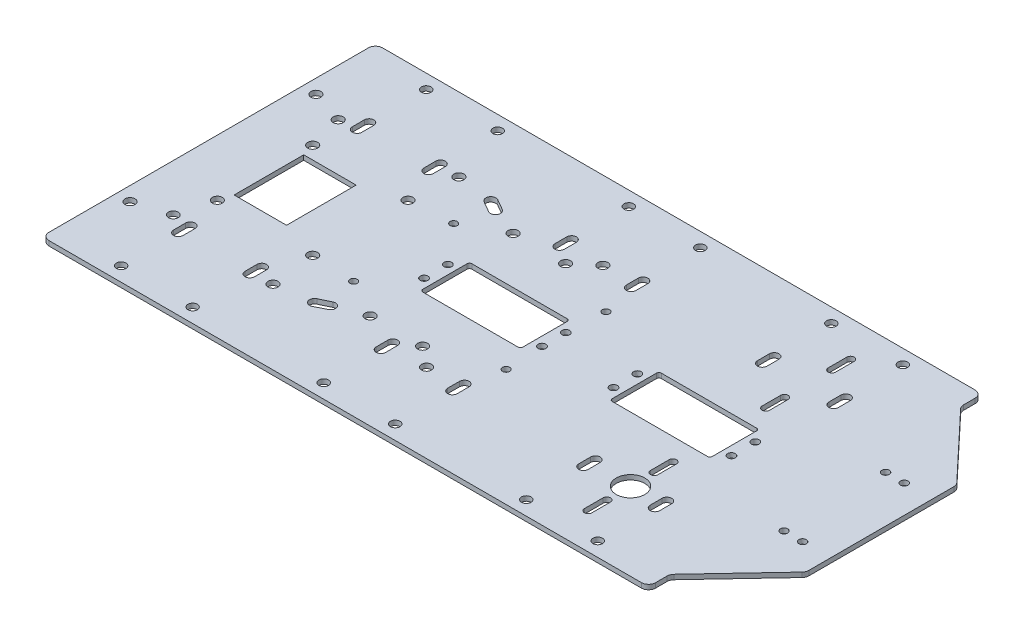
from build123d import *

# Parameters (mm, degrees)
SKETCH_1_R      = 2.1
SKETCH_1_R_2    = 2.05
SKETCH_1_R_3    = 1.55
SKETCH_1_R_4    = 2
SKETCH_1_R_5    = 1.6
SKETCH_1_R_6    = 1.5
SKETCH_1_R_7    = 6
SKETCH_1_W      = 22
SKETCH_1_H      = 29.2
EXTRUDE_1_DEPTH = 2


with BuildPart() as part:
    # 草图1 → 凸台-拉伸1 (new body)
    with BuildSketch(Plane(origin=(0, 0, 0), x_dir=(1, 0, 0), z_dir=(0, 1, 0))):
        with BuildLine():
            Line((4038.434618363, 1425.239502327), (4287.034512286, 1425.239502327))
            ThreePointArc((4287.034512286, 1425.239502327), (4289.15583263, 1426.118181984), (4290.034512286, 1428.239502327))
            Line((4290.034512286, 1428.239502327), (4290.034512286, 1433.049346517))
            ThreePointArc((4290.034512286, 1433.049346517), (4290.245938067, 1434.155625787), (4290.850414836, 1435.105974418))
            Line((4290.850414836, 1435.105974418), (4316.918828336, 1462.790105042))
            ThreePointArc((4316.918828336, 1462.790105042), (4317.523305104, 1463.740453674), (4317.734730885, 1464.846732944))
            Line((4317.734730885, 1464.846732944), (4317.734730885, 1525.653913947))
            ThreePointArc((4317.734730885, 1525.653913947), (4317.523305104, 1526.760193217), (4316.918828336, 1527.710541849))
            Line((4316.918828336, 1527.710541849), (4290.850414836, 1555.394672473))
            ThreePointArc((4290.850414836, 1555.394672473), (4290.245938067, 1556.345021104), (4290.034512286, 1557.451300374))
            Line((4290.034512286, 1557.451300374), (4290.034512286, 1562.261144564))
            ThreePointArc((4290.034512286, 1562.261144564), (4289.15583263, 1564.382464907), (4287.034512286, 1565.261144564))
            Line((4287.034512286, 1565.261144564), (4038.434618363, 1565.261144564))
            ThreePointArc((4038.434618363, 1565.261144564), (4036.313298019, 1564.382464907), (4035.434618363, 1562.261144564))
            Line((4035.434618363, 1562.261144564), (4035.434618363, 1428.239502327))
            ThreePointArc((4035.434618363, 1428.239502327), (4036.313298019, 1426.118181984), (4038.434618363, 1425.239502327))
        make_face()
        with Locations((4041.306274282, 1456.388343445)):
            Circle(SKETCH_1_R, mode=Mode.SUBTRACT)
        with Locations((4055.21317116, 1460.668720556)):
            Circle(SKETCH_1_R_2, mode=Mode.SUBTRACT)
        with Locations((4041.306274282, 1534.388343445)):
            Circle(SKETCH_1_R, mode=Mode.SUBTRACT)
        with Locations((4055.21317116, 1529.831926335)):
            Circle(SKETCH_1_R, mode=Mode.SUBTRACT)
        with Locations((4059.124286282, 1515.223338779)):
            Circle(SKETCH_1_R, mode=Mode.SUBTRACT)
        with Locations((4059.124286282, 1475.223338779)):
            Circle(SKETCH_1_R, mode=Mode.SUBTRACT)
        with Locations((4298.199059339, 1473.937422498)):
            Circle(SKETCH_1_R_3, mode=Mode.SUBTRACT)
        with Locations((4262.734565325, 1559.261144564)):
            Circle(SKETCH_1_R_4, mode=Mode.SUBTRACT)
        with Locations((4306.013069352, 1516.563224393)):
            Circle(SKETCH_1_R_3, mode=Mode.SUBTRACT)
        with Locations((4259.827612481, 1500.250323445)):
            Circle(SKETCH_1_R_5, mode=Mode.SUBTRACT)
        with Locations((4298.199059339, 1516.563224393)):
            Circle(SKETCH_1_R_3, mode=Mode.SUBTRACT)
        with Locations((4262.734565325, 1431.239502327)):
            Circle(SKETCH_1_R_4, mode=Mode.SUBTRACT)
        with Locations((4306.013069352, 1473.937422498)):
            Circle(SKETCH_1_R_3, mode=Mode.SUBTRACT)
        with Locations((4147.734565325, 1559.261144564)):
            Circle(SKETCH_1_R_4, mode=Mode.SUBTRACT)
        with Locations((4232.734565325, 1559.261144564)):
            Circle(SKETCH_1_R_4, mode=Mode.SUBTRACT)
        with Locations((4210.327612481, 1500.250323445)):
            Circle(SKETCH_1_R_5, mode=Mode.SUBTRACT)
        with Locations((4101.306274282, 1456.388343445)):
            Circle(SKETCH_1_R, mode=Mode.SUBTRACT)
        with Locations((4163.684053216, 1458.444726446)):
            Circle(SKETCH_1_R, mode=Mode.SUBTRACT)
        with Locations((4133.21317116, 1525.250323445)):
            Circle(SKETCH_1_R, mode=Mode.SUBTRACT)
        with Locations((4163.684053216, 1532.444726446)):
            Circle(SKETCH_1_R, mode=Mode.SUBTRACT)
        with Locations((4101.306274282, 1534.388343445)):
            Circle(SKETCH_1_R, mode=Mode.SUBTRACT)
        with Locations((4177.734565325, 1431.239502327)):
            Circle(SKETCH_1_R_4, mode=Mode.SUBTRACT)
        with Locations((4155.21317116, 1525.250323445)):
            Circle(SKETCH_1_R, mode=Mode.SUBTRACT)
        with Locations((4155.21317116, 1465.250323445)):
            Circle(SKETCH_1_R, mode=Mode.SUBTRACT)
        with Locations((4130.827612481, 1490.250323445)):
            Circle(SKETCH_1_R_5, mode=Mode.SUBTRACT)
        with Locations((4117.163901882, 1516.349188696)):
            Circle(SKETCH_1_R_6, mode=Mode.SUBTRACT)
        with Locations((4181.163901882, 1474.349188696)):
            Circle(SKETCH_1_R_6, mode=Mode.SUBTRACT)
        with Locations((4133.21317116, 1465.250323445)):
            Circle(SKETCH_1_R, mode=Mode.SUBTRACT)
        with Locations((4062.734565325, 1559.261144564)):
            Circle(SKETCH_1_R_4, mode=Mode.SUBTRACT)
        with Locations((4180.327612481, 1490.250323445)):
            Circle(SKETCH_1_R_5, mode=Mode.SUBTRACT)
        with Locations((4099.124286282, 1515.223338779)):
            Circle(SKETCH_1_R, mode=Mode.SUBTRACT)
        with Locations((4099.124286282, 1475.223338779)):
            Circle(SKETCH_1_R, mode=Mode.SUBTRACT)
        with Locations((4181.163901882, 1516.259188696)):
            Circle(SKETCH_1_R_6, mode=Mode.SUBTRACT)
        with Locations((4259.827612481, 1490.250323445)):
            Circle(SKETCH_1_R_5, mode=Mode.SUBTRACT)
        with Locations((4147.734565325, 1431.239502327)):
            Circle(SKETCH_1_R_4, mode=Mode.SUBTRACT)
        with Locations((4177.734565325, 1559.261144564)):
            Circle(SKETCH_1_R_4, mode=Mode.SUBTRACT)
        with Locations((4130.827612481, 1500.250323445)):
            Circle(SKETCH_1_R_5, mode=Mode.SUBTRACT)
        with Locations((4210.327612481, 1490.250323445)):
            Circle(SKETCH_1_R_5, mode=Mode.SUBTRACT)
        with Locations((4180.327612481, 1500.250323445)):
            Circle(SKETCH_1_R_5, mode=Mode.SUBTRACT)
        with Locations((4092.734565325, 1559.261144564)):
            Circle(SKETCH_1_R_4, mode=Mode.SUBTRACT)
        with Locations((4117.163901882, 1474.349188696)):
            Circle(SKETCH_1_R_6, mode=Mode.SUBTRACT)
        with Locations((4249.740991595, 1457.978301065)):
            Circle(SKETCH_1_R_7, mode=Mode.SUBTRACT)
        with Locations((4232.734565325, 1431.239502327)):
            Circle(SKETCH_1_R_4, mode=Mode.SUBTRACT)
        with Locations((4092.734565325, 1431.239502327)):
            Circle(SKETCH_1_R_4, mode=Mode.SUBTRACT)
        with Locations((4062.734565325, 1431.239502327)):
            Circle(SKETCH_1_R_4, mode=Mode.SUBTRACT)
        with Locations((4071.728935132, 1495.250323445)):
            Rectangle(SKETCH_1_W, SKETCH_1_H, mode=Mode.SUBTRACT)
        with BuildLine():
            Line((4175.734565325, 1460.250323445), (4175.734565325, 1455.239502327))
            ThreePointArc((4175.734565325, 1455.239502327), (4177.734565325, 1453.239502327), (4179.734565325, 1455.239502327))
            Line((4179.734565325, 1455.239502327), (4179.734565325, 1460.250323445))
            ThreePointArc((4179.734565325, 1460.250323445), (4177.734565325, 1462.250323445), (4175.734565325, 1460.250323445))
        make_face(mode=Mode.SUBTRACT)
        with BuildLine():
            Line((4145.734565325, 1460.250323445), (4145.734565325, 1455.239502327))
            ThreePointArc((4145.734565325, 1455.239502327), (4147.734565325, 1453.239502327), (4149.734565325, 1455.239502327))
            Line((4149.734565325, 1455.239502327), (4149.734565325, 1460.250323445))
            ThreePointArc((4149.734565325, 1460.250323445), (4147.734565325, 1462.250323445), (4145.734565325, 1460.250323445))
        make_face(mode=Mode.SUBTRACT)
        with BuildLine():
            Line((4115.634682032, 1530.625710196), (4120.163799976, 1528.012910085))
            ThreePointArc((4120.163799976, 1528.012910085), (4123.03218741, 1528.78255515), (4122.262542344, 1531.650942585))
            Line((4122.262542344, 1531.650942585), (4117.7334244, 1534.263742696))
            ThreePointArc((4117.7334244, 1534.263742696), (4114.865036966, 1533.49409763), (4115.634682032, 1530.625710196))
        make_face(mode=Mode.SUBTRACT)
        with BuildLine():
            Line((4094.734565325, 1455.239502327), (4094.734565325, 1460.250323445))
            ThreePointArc((4094.734565325, 1460.250323445), (4092.734565325, 1462.250323445), (4090.734565325, 1460.250323445))
            Line((4090.734565325, 1460.250323445), (4090.734565325, 1455.239502327))
            ThreePointArc((4090.734565325, 1455.239502327), (4092.734565325, 1453.239502327), (4094.734565325, 1455.239502327))
        make_face(mode=Mode.SUBTRACT)
        with BuildLine():
            Line((4060.734565325, 1460.250323445), (4060.734565325, 1455.239502327))
            ThreePointArc((4060.734565325, 1455.239502327), (4062.734565325, 1453.239502327), (4064.734565325, 1455.239502327))
            Line((4064.734565325, 1455.239502327), (4064.734565325, 1460.250323445))
            ThreePointArc((4064.734565325, 1460.250323445), (4062.734565325, 1462.250323445), (4060.734565325, 1460.250323445))
        make_face(mode=Mode.SUBTRACT)
        with BuildLine():
            Line((4234.734565325, 1455.239502327), (4234.734565325, 1460.250323445))
            ThreePointArc((4234.734565325, 1460.250323445), (4232.734565325, 1462.250323445), (4230.734565325, 1460.250323445))
            Line((4230.734565325, 1460.250323445), (4230.734565325, 1455.239502327))
            ThreePointArc((4230.734565325, 1455.239502327), (4232.734565325, 1453.239502327), (4234.734565325, 1455.239502327))
        make_face(mode=Mode.SUBTRACT)
        with BuildLine():
            Line((4090.734565325, 1530.250323445), (4090.734565325, 1535.261144564))
            ThreePointArc((4090.734565325, 1535.261144564), (4092.734565325, 1537.261144564), (4094.734565325, 1535.261144564))
            Line((4094.734565325, 1535.261144564), (4094.734565325, 1530.250323445))
            ThreePointArc((4094.734565325, 1530.250323445), (4092.734565325, 1528.250323445), (4090.734565325, 1530.250323445))
        make_face(mode=Mode.SUBTRACT)
        with BuildLine():
            Line((4176.577612481, 1504.550323445), (4176.577612481, 1485.950323445))
            ThreePointArc((4176.577612481, 1485.950323445), (4176.284719262, 1485.243216664), (4175.577612481, 1484.950323445))
            Line((4175.577612481, 1484.950323445), (4135.577612481, 1484.950323445))
            ThreePointArc((4135.577612481, 1484.950323445), (4134.870505699, 1485.243216664), (4134.577612481, 1485.950323445))
            Line((4134.577612481, 1485.950323445), (4134.577612481, 1504.550323445))
            ThreePointArc((4134.577612481, 1504.550323445), (4134.870505699, 1505.257430227), (4135.577612481, 1505.550323445))
            Line((4135.577612481, 1505.550323445), (4175.577612481, 1505.550323445))
            ThreePointArc((4175.577612481, 1505.550323445), (4176.284719262, 1505.257430227), (4176.577612481, 1504.550323445))
        make_face(mode=Mode.SUBTRACT)
        with BuildLine():
            Line((4115.777160046, 1460.338807959), (4120.327870684, 1462.517704891))
            ThreePointArc((4120.327870684, 1462.517704891), (4123.053291883, 1461.572299952), (4122.134940744, 1458.837644142))
            Line((4122.134940744, 1458.837644142), (4117.628304985, 1456.568989631))
            ThreePointArc((4117.628304985, 1456.568989631), (4114.7990515, 1457.519108529), (4115.777160046, 1460.338807959))
        make_face(mode=Mode.SUBTRACT)
        with BuildLine():
            Line((4149.734565325, 1535.261144564), (4149.734565325, 1530.250323445))
            ThreePointArc((4149.734565325, 1530.250323445), (4147.734565325, 1528.250323445), (4145.734565325, 1530.250323445))
            Line((4145.734565325, 1530.250323445), (4145.734565325, 1535.261144564))
            ThreePointArc((4145.734565325, 1535.261144564), (4147.734565325, 1537.261144564), (4149.734565325, 1535.261144564))
        make_face(mode=Mode.SUBTRACT)
        with BuildLine():
            Line((4060.734565325, 1530.250323445), (4060.734565325, 1535.261144564))
            ThreePointArc((4060.734565325, 1535.261144564), (4062.734565325, 1537.261144564), (4064.734565325, 1535.261144564))
            Line((4064.734565325, 1535.261144564), (4064.734565325, 1530.250323445))
            ThreePointArc((4064.734565325, 1530.250323445), (4062.734565325, 1528.250323445), (4060.734565325, 1530.250323445))
        make_face(mode=Mode.SUBTRACT)
        with BuildLine():
            Line((4175.734565325, 1530.250323445), (4175.734565325, 1535.261144564))
            ThreePointArc((4175.734565325, 1535.261144564), (4177.734565325, 1537.261144564), (4179.734565325, 1535.261144564))
            Line((4179.734565325, 1535.261144564), (4179.734565325, 1530.250323445))
            ThreePointArc((4179.734565325, 1530.250323445), (4177.734565325, 1528.250323445), (4175.734565325, 1530.250323445))
        make_face(mode=Mode.SUBTRACT)
        with BuildLine():
            Line((4251.290991595, 1514.763224393), (4251.290991595, 1522.553887451))
            ThreePointArc((4251.290991595, 1522.553887451), (4249.740991595, 1524.103887451), (4248.190991595, 1522.553887451))
            Line((4248.190991595, 1522.553887451), (4248.190991595, 1514.763224393))
            ThreePointArc((4248.190991595, 1514.763224393), (4249.740991595, 1513.213223205), (4251.290991595, 1514.763224393))
        make_face(mode=Mode.SUBTRACT)
        with BuildLine():
            Line((4251.290991595, 1542.490804201), (4251.290991595, 1550.28146726))
            ThreePointArc((4251.290991595, 1550.28146726), (4249.740991595, 1551.83146726), (4248.190991595, 1550.28146726))
            Line((4248.190991595, 1550.28146726), (4248.190991595, 1542.490804201))
            ThreePointArc((4248.190991595, 1542.490804201), (4249.740991595, 1540.940803014), (4251.290991595, 1542.490804201))
        make_face(mode=Mode.SUBTRACT)
        with BuildLine():
            Line((4260.734565325, 1460.250323445), (4260.734565325, 1455.239502327))
            ThreePointArc((4260.734565325, 1455.239502327), (4262.734565325, 1453.239502327), (4264.734565325, 1455.239502327))
            Line((4264.734565325, 1455.239502327), (4264.734565325, 1460.250323445))
            ThreePointArc((4264.734565325, 1460.250323445), (4262.734565325, 1462.250323445), (4260.734565325, 1460.250323445))
        make_face(mode=Mode.SUBTRACT)
        with BuildLine():
            Line((4256.077612481, 1504.550323445), (4256.077612481, 1485.950323445))
            ThreePointArc((4256.077612481, 1485.950323445), (4255.784719262, 1485.243216664), (4255.077612481, 1484.950323445))
            Line((4255.077612481, 1484.950323445), (4215.077612481, 1484.950323445))
            ThreePointArc((4215.077612481, 1484.950323445), (4214.370505699, 1485.243216664), (4214.077612481, 1485.950323445))
            Line((4214.077612481, 1485.950323445), (4214.077612481, 1504.550323445))
            ThreePointArc((4214.077612481, 1504.550323445), (4214.370505699, 1505.257430227), (4215.077612481, 1505.550323445))
            Line((4215.077612481, 1505.550323445), (4255.077612481, 1505.550323445))
            ThreePointArc((4255.077612481, 1505.550323445), (4255.784719262, 1505.257430227), (4256.077612481, 1504.550323445))
        make_face(mode=Mode.SUBTRACT)
        with BuildLine():
            Line((4230.734565325, 1530.250323445), (4230.734565325, 1535.261144564))
            ThreePointArc((4230.734565325, 1535.261144564), (4232.734565325, 1537.261144564), (4234.734565325, 1535.261144564))
            Line((4234.734565325, 1535.261144564), (4234.734565325, 1530.250323445))
            ThreePointArc((4234.734565325, 1530.250323445), (4232.734565325, 1528.250323445), (4230.734565325, 1530.250323445))
        make_face(mode=Mode.SUBTRACT)
        with BuildLine():
            Line((4260.734565325, 1530.250323445), (4260.734565325, 1535.261144564))
            ThreePointArc((4260.734565325, 1535.261144564), (4262.734565325, 1537.261144564), (4264.734565325, 1535.261144564))
            Line((4264.734565325, 1535.261144564), (4264.734565325, 1530.250323445))
            ThreePointArc((4264.734565325, 1530.250323445), (4262.734565325, 1528.250323445), (4260.734565325, 1530.250323445))
        make_face(mode=Mode.SUBTRACT)
        with BuildLine():
            Line((4248.190991595, 1467.94675944), (4248.190991595, 1475.737422498))
            ThreePointArc((4248.190991595, 1475.737422498), (4249.740991595, 1477.287422498), (4251.290991595, 1475.737422498))
            Line((4251.290991595, 1475.737422498), (4251.290991595, 1467.94675944))
            ThreePointArc((4251.290991595, 1467.94675944), (4249.740991595, 1466.396758253), (4248.190991595, 1467.94675944))
        make_face(mode=Mode.SUBTRACT)
        with BuildLine():
            Line((4248.190991595, 1440.219179631), (4248.190991595, 1448.00984269))
            ThreePointArc((4248.190991595, 1448.00984269), (4249.740991595, 1449.55984269), (4251.290991595, 1448.00984269))
            Line((4251.290991595, 1448.00984269), (4251.290991595, 1440.219179631))
            ThreePointArc((4251.290991595, 1440.219179631), (4249.740991595, 1438.669178444), (4248.190991595, 1440.219179631))
        make_face(mode=Mode.SUBTRACT)
    extrude(amount=EXTRUDE_1_DEPTH)


solid = part.part
